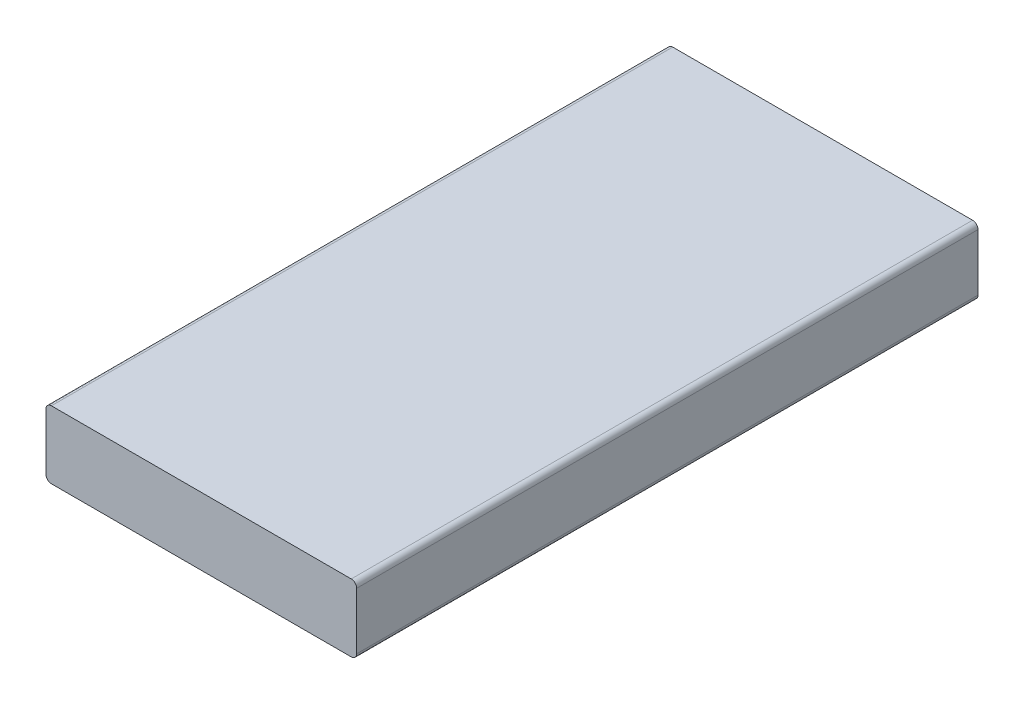
from build123d import *

# Parameters (mm, degrees)
SKETCH1_W           = 115
SKETCH1_H           = 25
BOSS_EXTRUDE1_DEPTH = 230
FILLET1_R           = 2


with BuildPart() as part:
    # Sketch1 → Boss-Extrude1 (new body)
    with BuildSketch(Plane.XY):
        with Locations((28.159722222, 3.385416667)):
            Rectangle(SKETCH1_W, SKETCH1_H)
    extrude(amount=-BOSS_EXTRUDE1_DEPTH)

    # Fillet1
    fillet1_edges = [part.edges().sort_by_distance(p)[0] for p in [
        (-29.340277778, 15.885416667, -115),
        (85.659722222, 15.885416667, -115),
        (85.659722222, -9.114583333, -115),
        (-29.340277778, -9.114583333, -115),
    ]]
    fillet(fillet1_edges, radius=FILLET1_R)


solid = part.part
